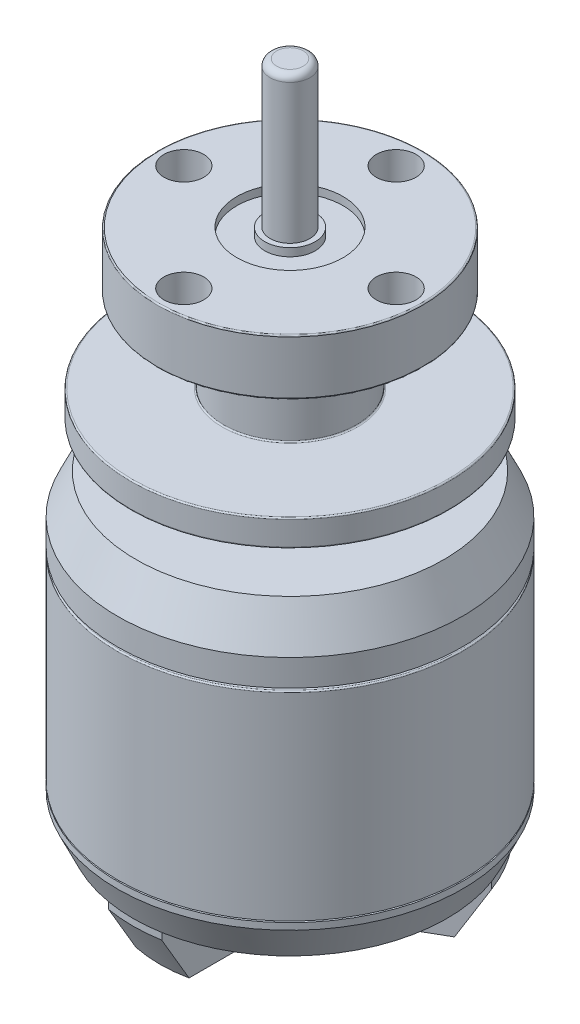
from build123d import *
from OCP.BRepFilletAPI import BRepFilletAPI_MakeChamfer

# Parameters (mm, degrees)
SKETCH1_R            = 13
BOSS_EXTRUDE1_DEPTH  = 15
SKETCH2_R            = 7
BOSS_EXTRUDE2_DEPTH  = 0.2
SKETCH4_R            = 13.000000000000004
BOSS_EXTRUDE3_DEPTH  = 5
SKETCH5_R            = 5
BOSS_EXTRUDE4_DEPTH  = 3.4
SKETCH6_R            = 12
BOSS_EXTRUDE5_DEPTH  = 2
SKETCH7_R            = 5
BOSS_EXTRUDE6_DEPTH  = 6.3
SKETCH8_R            = 10
BOSS_EXTRUDE7_DEPTH  = 4.2
CHAMFER1_SIZE        = 3
CHAMFER1_SIZE2       = 1.3989229744649996
FILLET1_R            = 0.1
SKETCH9_R            = 8.463574214087313
BOSS_EXTRUDE8_DEPTH  = 0.1
BOSS_EXTRUDE9_START  = 3
SKETCH10_R           = 13.000000000000004
BOSS_EXTRUDE9_DEPTH  = 3
CHAMFER2_SIZE        = 2.5
CHAMFER2_SIZE2       = 1.1657691453874992
BOSS_EXTRUDE10_START = 4
BOSS_EXTRUDE10_DEPTH = 4
CHAMFER3_SIZE        = 3.5
CHAMFER3_SIZE2       = 2.0207259421636956
SKETCH13_R           = 10.77059477245057
CUT_EXTRUDE1_DEPTH   = 4
SKETCH14_R           = 4.5
BOSS_EXTRUDE11_DEPTH = 1
FILLET2_R            = 0.7
FILLET3_R            = 2
SKETCH15_R           = 1.5000000000000002
CUT_EXTRUDE2_DEPTH   = 4
CIRPATTERN1_COUNT    = 3
SKETCH16_R           = 1.7
SKETCH16_R_2         = 1.5
CUT_EXTRUDE3_DEPTH   = 2
FILLET4_R            = 0.3
SKETCH17_R           = 4
SKETCH17_R_2         = 1.9
CUT_EXTRUDE4_DEPTH   = 0.6
SKETCH18_R           = 1.5
BOSS_EXTRUDE12_DEPTH = 11
FILLET5_R            = 0.5
SKETCH19_R           = 1.4999999999999998
CUT_EXTRUDE5_DEPTH   = 5
CIRPATTERN2_COUNT    = 4


with BuildPart() as part:
    # Sketch1 → Boss-Extrude1 (new body)
    with BuildSketch(Plane(origin=(0, 0, 0), x_dir=(1, 0, 0), z_dir=(0, 1, 0))):
        with Locations(Location((0, 0, 0), (0, 0, 270))):
            Circle(SKETCH1_R)
    extrude(amount=BOSS_EXTRUDE1_DEPTH)

    # Sketch2 → Boss-Extrude2 (add)
    with BuildSketch(Plane(origin=(0, 15, 0), x_dir=(1, 0, 0), z_dir=(0, 1, 0))):
        with Locations(Location((0, 0, 0), (0, 0, 270))):
            Circle(SKETCH2_R)
    extrude(amount=BOSS_EXTRUDE2_DEPTH)

    # Sketch4 → Boss-Extrude3 (add)
    with BuildSketch(Plane(origin=(0, 15.2, 0), x_dir=(1, 0, 0), z_dir=(0, 1, 0))):
        with Locations(Location((0, 0, 0), (0, 0, 270))):
            Circle(SKETCH4_R)
    extrude(amount=BOSS_EXTRUDE3_DEPTH)

    # Sketch5 → Boss-Extrude4 (add)
    with BuildSketch(Plane(origin=(0, 20.2, 0), x_dir=(1, 0, 0), z_dir=(0, 1, 0))):
        with Locations(Location((0, 0, 0), (0, 0, 270))):
            Circle(SKETCH5_R)
    extrude(amount=BOSS_EXTRUDE4_DEPTH)

    # Sketch6 → Boss-Extrude5 (add)
    with BuildSketch(Plane(origin=(0, 23.599999999999998, 0), x_dir=(1, 0, 0), z_dir=(0, 1, 0))):
        with Locations(Location((0, 0, 0), (0, 0, 270))):
            Circle(SKETCH6_R)
    extrude(amount=BOSS_EXTRUDE5_DEPTH)

    # Sketch7 → Boss-Extrude6 (add)
    with BuildSketch(Plane(origin=(0, 25.599999999999998, 0), x_dir=(1, 0, 0), z_dir=(0, 1, 0))):
        with Locations(Location((0, 0, 0), (0, 0, 270))):
            Circle(SKETCH7_R)
    extrude(amount=BOSS_EXTRUDE6_DEPTH)

    # Sketch8 → Boss-Extrude7 (add)
    with BuildSketch(Plane(origin=(0, 31.9, 0), x_dir=(1, 0, 0), z_dir=(0, 1, 0))):
        with Locations(Location((0, 0, 0), (0, 0, 270))):
            Circle(SKETCH8_R)
    extrude(amount=BOSS_EXTRUDE7_DEPTH)

    # Chamfer1
    chamfer1_edges = [part.edges().sort_by_distance(p)[0] for p in [
        (3.98e-15, 20.2, -13.000000000000004),
    ]]
    chamfer1_side = [part.faces().sort_by_distance(p)[0] for p in [
        (3.98e-15, 17.7, -13.000000000000004),
    ]]
    chamfer(chamfer1_edges, length=CHAMFER1_SIZE, length2=CHAMFER1_SIZE2, reference=chamfer1_side[0])

    # Fillet1
    fillet1_edges = [part.edges().sort_by_distance(p)[0] for p in [
        (1.53e-15, 20.2, -5),
        (1.53e-15, 23.599999999999998, -5),
        (3.67e-15, 23.599999999999998, -12),
        (3.67e-15, 25.599999999999998, -12),
        (1.53e-15, 25.599999999999998, -5),
        (1.53e-15, 31.9, -5),
        (3.06e-15, 31.9, -10),
        (3.06e-15, 36.1, -10),
        (-1.79e-15, 15, -13),
    ]]
    fillet(fillet1_edges, radius=FILLET1_R)

    # Sketch9 → Boss-Extrude8 (add)
    with BuildSketch(Plane.XZ):
        with Locations(Location((0, 0, 0), (0, 0, 270))):
            Circle(SKETCH9_R)
    extrude(amount=BOSS_EXTRUDE8_DEPTH)

    # Sketch10 → Boss-Extrude9 (add)
    with BuildSketch(Plane.XZ.offset(0.1).offset(BOSS_EXTRUDE9_START)):
        with Locations(Location((0, 0, 0), (0, 0, 90))):
            Circle(SKETCH10_R)
    extrude(amount=-BOSS_EXTRUDE9_DEPTH)

    # Chamfer2
    chamfer2_edges = [part.edges().sort_by_distance(p)[0] for p in [
        (-2.39e-15, -3.1, -13.000000000000004),
    ]]
    chamfer2_side = [part.faces().sort_by_distance(p)[0] for p in [
        (-2.39e-15, -1.6, -13.000000000000004),
    ]]
    chamfer(chamfer2_edges, length=CHAMFER2_SIZE, length2=CHAMFER2_SIZE2, reference=chamfer2_side[0])

    # Sketch12 → Boss-Extrude10 (add)
    with BuildSketch(Plane.XZ.offset(3.1).offset(BOSS_EXTRUDE10_START)):
        with BuildLine():
            Line((-4.968626966596926, -0.5592370399090334), (-11.10132491013915, -4.099951848471753))
            ThreePointArc((-11.1013249101391, -4.099951848471809), (-10.713631015383742, -5.026642058717716), (-10.248744788504228, -5.917115021728898))
            ThreePointArc((-10.248744788504228, -5.917115021728898), (-9.710015493984855, -6.764955212478231), (-9.101324910139237, -7.564053463609399))
            Line((-9.101324910139185, -7.56405346360953), (-2.9686269665968643, -4.023338655046755))
            ThreePointArc((-2.96862696659685, -4.023338655046824), (-4.330127018922175, -2.5000000000000315), (-4.968626966596883, -0.5592370399090708))
        make_face()
        with BuildLine():
            Line((-2.0000000000000036, 1.1547005383792586), (-4.968626966596926, -0.5592370399090334))
            ThreePointArc((-4.968626966596883, -0.5592370399090708), (-4.330127018922175, -2.5000000000000315), (-2.96862696659685, -4.023338655046824))
            Line((-2.9686269665968643, -4.023338655046755), (-3.55e-15, -2.3094010767584994))
            Line((-5.33e-15, -2.3094010767585016), (-1.000000000000002, -1.7320508075688765))
            Line((-1.000000000000002, -1.7320508075688765), (4.4e-16, 2.2e-16))
            Line((0, 2.3e-16), (-2, -1e-17))
            Line((-2, -1e-17), (-2, 1.15470053837926))
        make_face()
        with BuildLine():
            Line((-3.55e-15, -2.3094010767584994), (-2.9686269665968643, -4.023338655046755))
            ThreePointArc((-2.96862696659685, -4.023338655046824), (-1.868e-14, -5), (2.96862696659682, -4.023338655046846))
            Line((2.968626966596837, -4.023338655046775), (-5.33e-15, -2.3094010767585016))
        make_face()
        with BuildLine():
            Line((0.9999999999999911, -1.7320508075688847), (-3.55e-15, -2.3094010767584994))
            Line((-5.33e-15, -2.3094010767585016), (2.968626966596837, -4.023338655046775))
            ThreePointArc((2.96862696659682, -4.023338655046846), (4.330127018922203, -2.499999999999983), (4.968626966596899, -0.559237039908927))
            Line((4.968626966596811, -0.5592370399090061), (2.0000000000000027, 1.1547005383792481))
            Line((2.000000000000002, 1.1547005383792481), (2.0000000000000027, 4.8e-16))
            Line((2.0000000000000027, 4.8e-16), (0, 2.3e-16))
            Line((2.2e-16, -2.2e-16), (0.9999999999999907, -1.7320508075688847))
        make_face()
        with BuildLine():
            Line((2.968626966596837, -4.023338655046775), (9.10132491013913, -7.564053463609591))
            ThreePointArc((9.101324910139173, -7.564053463609475), (9.710015458843332, -6.76495526291829), (10.248744727029683, -5.917115128205941))
            ThreePointArc((10.248744727029683, -5.917115128205941), (10.713630989272133, -5.026642114371199), (11.101324910139066, -4.0999518484719015))
            Line((11.101324910139121, -4.099951848471832), (4.968626966596811, -0.5592370399090061))
            ThreePointArc((4.968626966596899, -0.559237039908927), (4.330127018922203, -2.499999999999983), (2.96862696659682, -4.023338655046846))
        make_face()
        Polygon((-1.000000000000002, -1.7320508075688765), (-5.33e-15, -2.3094010767585016), (0.9999999999999911, -1.7320508075688847), (2.2e-16, -2.2e-16), align=None)
        Polygon((1.000000000000002, 1.7320508075688756), (4.4e-16, 2.2e-16), (2.0000000000000027, 4.8e-16), (2.000000000000002, 1.1547005383792481), align=None)
        with BuildLine():
            ThreePointArc((5, 0), (4.183300132670404, 2.738612787525792), (2.0000000000000853, 4.5825756949558025))
            Line((2.0000000000000018, 4.582575694955776), (2.000000000000002, 1.1547005383792481))
            Line((2.0000000000000027, 1.1547005383792481), (4.968626966596811, -0.5592370399090061))
            ThreePointArc((4.968626966596899, -0.559237039908927), (4.992150580310278, -0.28005817879104034), (5, -1.22e-15))
        make_face()
        with BuildLine():
            Line((-2, 4.582575694955866), (-2, 1.15470053837926))
            Line((-2.0000000000000036, 1.1547005383792586), (-0.9999999999999911, 1.7320508075688839))
            Line((-0.9999999999999902, 1.7320508075688843), (2.2e-16, -2.2e-16))
            Line((4.4e-16, 2.2e-16), (1.000000000000002, 1.7320508075688756))
            Line((1.000000000000002, 1.7320508075688756), (2.0000000000000027, 1.1547005383792481))
            Line((2.000000000000002, 1.1547005383792481), (2.0000000000000018, 4.582575694955776))
            ThreePointArc((2.0000000000000853, 4.5825756949558025), (6.47e-14, 5), (-1.9999999999999662, 4.582575694955855))
        make_face()
        with BuildLine():
            ThreePointArc((-1.9999999999999662, 4.582575694955855), (-4.330127018922191, 2.500000000000004), (-4.968626966596883, -0.5592370399090708))
            Line((-4.968626966596926, -0.5592370399090334), (-2.0000000000000036, 1.1547005383792586))
            Line((-2, 1.15470053837926), (-2, 4.582575694955866))
        make_face()
        with BuildLine():
            ThreePointArc((5.853e-14, 11.834230854612493), (-1.0036155557942605, 11.791597675312286), (-1.9999999999997802, 11.664005312081404))
            Line((-2, 11.66400531208144), (-2, 4.582575694955866))
            ThreePointArc((-1.9999999999999662, 4.582575694955855), (6.47e-14, 5), (2.0000000000000853, 4.5825756949558025))
            Line((2.0000000000000018, 4.582575694955776), (2, 11.664005312081269))
            ThreePointArc((2.0000000000002918, 11.664005312081317), (1.0036155557945787, 11.791597675312259), (5.853e-14, 11.834230854612493))
        make_face()
        Polygon((-0.9999999999999911, 1.7320508075688839), (-2.0000000000000036, 1.1547005383792586), (-2, -1e-17), (0, 2.3e-16), align=None)
    extrude(amount=-BOSS_EXTRUDE10_DEPTH)

    # Chamfer3: one chamfer whose edges measure the first distance from different faces: ONE call of the kernel's chamfer builder (chamfer() names one face for all edges)
    chamfer3_edges_1 = [part.edges().sort_by_distance(p)[0] for p in [
        (10.248744554344045, -7.1, -5.917115427306248),
    ]]
    chamfer3_side_1 = [part.faces().sort_by_distance(p)[0] for p in [
        (10.248744554344047, -5.1, -5.917115427306248),
    ]]
    chamfer3_edges_2 = [part.edges().sort_by_distance(p)[0] for p in [
        (1.3683e-13, -7.1, 11.834230854612489),
    ]]
    chamfer3_side_2 = [part.faces().sort_by_distance(p)[0] for p in [
        (2.936e-13, -5.1, 11.834230854612489),
    ]]
    chamfer3_edges_3 = [part.edges().sort_by_distance(p)[0] for p in [
        (-10.24874455434409, -7.1, -5.917115427306171),
    ]]
    chamfer3_side_3 = [part.faces().sort_by_distance(p)[0] for p in [
        (-10.24874455434409, -5.1, -5.9171154273061735),
    ]]
    chamfer3 = BRepFilletAPI_MakeChamfer(part.part.solid().wrapped)
    for e in chamfer3_edges_1:
        chamfer3.Add(CHAMFER3_SIZE, CHAMFER3_SIZE2, e.wrapped, chamfer3_side_1[0].wrapped)  # the first distance lies on this face
    for e in chamfer3_edges_2:
        chamfer3.Add(CHAMFER3_SIZE, CHAMFER3_SIZE2, e.wrapped, chamfer3_side_2[0].wrapped)  # the first distance lies on this face
    for e in chamfer3_edges_3:
        chamfer3.Add(CHAMFER3_SIZE, CHAMFER3_SIZE2, e.wrapped, chamfer3_side_3[0].wrapped)  # the first distance lies on this face
    add(Compound.cast(chamfer3.Shape()), mode=Mode.REPLACE)

    # Sketch13 → Cut-Extrude1 (cut)
    with BuildSketch(Plane.XZ.offset(3.1)):
        with Locations(Location((0, 0, 0), (0, 0, 270))):
            Circle(SKETCH13_R)
    extrude(amount=-CUT_EXTRUDE1_DEPTH, mode=Mode.SUBTRACT)


with BuildPart() as cut_extrude1_piece_1:
    # of the separate pieces the step leaves, piece 1, a body of its own (cut_extrude1_pieces)
    add(part.part.solids().sort_by_distance((0, 0, 13))[0])

    # Sketch17 → Cut-Extrude4 (cut)
    with BuildSketch(Plane(origin=(0, 36.1, 0), x_dir=(1, 0, 0), z_dir=(0, 1, 0))):
        with Locations(Location((0, 0, 0), (0, 0, 270))):
            Circle(SKETCH17_R)
        with Locations(Location((0, 0, 0), (0, 0, 270))):
            Circle(SKETCH17_R_2, mode=Mode.SUBTRACT)
    extrude(amount=-CUT_EXTRUDE4_DEPTH, mode=Mode.SUBTRACT)

    # Sketch18 → Boss-Extrude12 (add)
    with BuildSketch(Plane(origin=(0, 36.1, 0), x_dir=(1, 0, 0), z_dir=(0, 1, 0))):
        with Locations(Location((0, 0, 0), (0, 0, 270))):
            Circle(SKETCH18_R)
    extrude(amount=BOSS_EXTRUDE12_DEPTH)

    # Fillet5
    fillet5_edges = [cut_extrude1_piece_1.edges().sort_by_distance(p)[0] for p in [
        (4.6e-16, 47.1, -1.5),
    ]]
    fillet(fillet5_edges, radius=FILLET5_R)

    # Sketch19 → Cut-Extrude5 (cut)
    with BuildSketch(Plane(origin=(0, 36.1, 0), x_dir=(1, 0, 0), z_dir=(0, 1, 0))):
        with Locations(Location((0, 8, 0), (0, 0, 270))):
            Circle(SKETCH19_R)
    cut_extrude5 = extrude(amount=-CUT_EXTRUDE5_DEPTH, mode=Mode.SUBTRACT)

    # CirPattern2: Cut-Extrude5 ×4 about axis
    cirpattern2_axis = Axis((-1.397e-14, 0, 0), (0, 1, 0))
    for i in range(1, CIRPATTERN2_COUNT):
        add(cut_extrude5.rotate(cirpattern2_axis, i * 360 / CIRPATTERN2_COUNT), mode=Mode.SUBTRACT)


with BuildPart() as cut_extrude1_piece_2:
    # of the separate pieces the step leaves, piece 2, a body of its own (cut_extrude1_pieces)
    add(part.part.solids().sort_by_distance((2, -3.6, 11.664005312))[0])

    # Sketch14 → Boss-Extrude11 (add)
    with BuildSketch(Plane.XZ.offset(7.1000000000000005)):
        with Locations(Location((0, 0, 0), (0, 0, 270))):
            Circle(SKETCH14_R)
    extrude(amount=BOSS_EXTRUDE11_DEPTH)

    # Fillet2
    fillet2_edges = [cut_extrude1_piece_2.edges().sort_by_distance(p)[0] for p in [
        (1.38e-15, -8.100000000000001, 4.5),
    ]]
    fillet(fillet2_edges, radius=FILLET2_R)

    # Fillet3
    fillet3_edges = [cut_extrude1_piece_2.edges().sort_by_distance(p)[0] for p in [
        (-2.968626966596857, -5.1, -4.023338655046789),
        (2.968626966596829, -5.1, -4.02333865504681),
        (4.9686269665968545, -5.1, -0.5592370399089666),
        (2.0000000000000435, -5.1, 4.582575694955789),
        (-1.9999999999999831, -5.1, 4.58257569495586),
        (-4.968626966596904, -5.1, -0.5592370399090523),
    ]]
    fillet(fillet3_edges, radius=FILLET3_R)

    # Sketch15 → Cut-Extrude2 (cut)
    with BuildSketch(Plane.XZ.offset(7.1000000000000005)):
        with Locations(Location((0, 6.5, 0), (0, 0, 270))):
            Circle(SKETCH15_R)
    cut_extrude2 = extrude(amount=-CUT_EXTRUDE2_DEPTH, mode=Mode.SUBTRACT)

    # CirPattern1: Cut-Extrude2 ×3 about axis
    cirpattern1_axis = Axis((-9e-17, 0, -3.4e-16), (0, 1, 0))
    for i in range(1, CIRPATTERN1_COUNT):
        add(cut_extrude2.rotate(cirpattern1_axis, i * 360 / CIRPATTERN1_COUNT), mode=Mode.SUBTRACT)

    # Sketch16 → Cut-Extrude3 (cut)
    with BuildSketch(Plane.XZ.offset(8.1)):
        with Locations(Location((0, 0, 0), (0, 0, 270))):
            Circle(SKETCH16_R)
        with Locations(Location((0, 0, 0), (0, 0, 270))):
            Circle(SKETCH16_R_2, mode=Mode.SUBTRACT)
    extrude(amount=-CUT_EXTRUDE3_DEPTH, mode=Mode.SUBTRACT)

    # Fillet4
    fillet4_edges = [cut_extrude1_piece_2.edges().sort_by_distance(p)[0] for p in [
        (4.6e-16, -8.1, 1.5),
    ]]
    fillet(fillet4_edges, radius=FILLET4_R)


solid = Compound([cut_extrude1_piece_1.part, cut_extrude1_piece_2.part])
